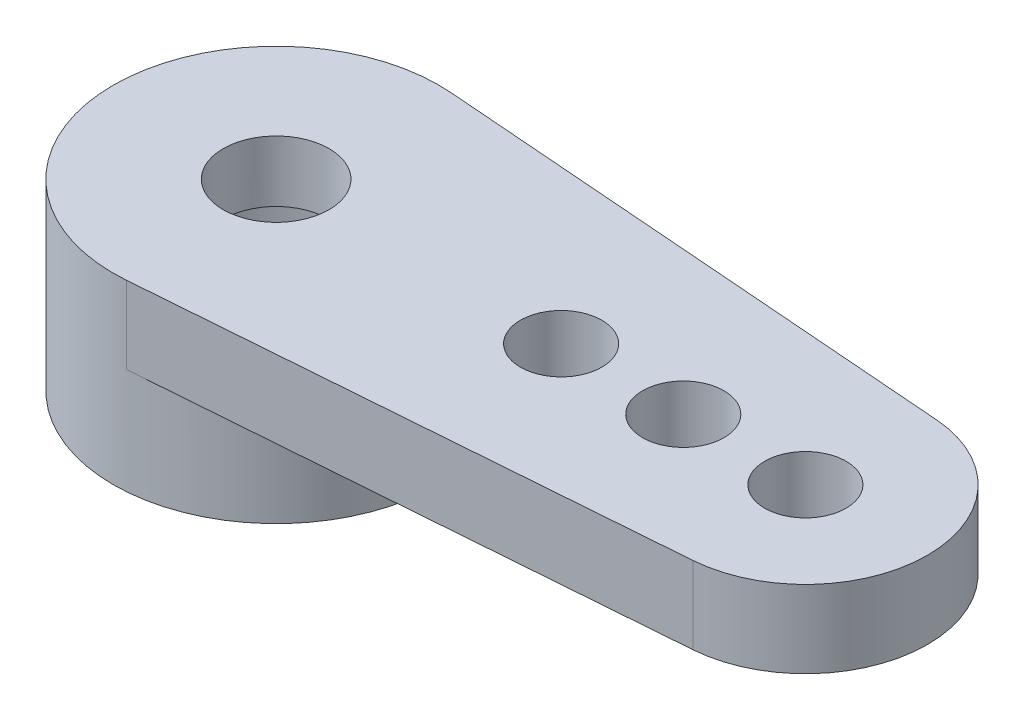
from build123d import *

# Parameters (mm, degrees)
SKETCH_1_R          = 4
SKETCH_1_R_2        = 1.3
EXTRUDE_1_DEPTH     = 4.5
SKETCH_2_R          = 1
EXTRUDE_2_DEPTH     = 1.9
SKETCH_3_R          = 3
CUT_EXTRUDE_1_DEPTH = 3


with BuildPart() as part:
    # 草图1 → 凸台-拉伸1 (new body)
    with BuildSketch(Plane(origin=(0, 0, 0), x_dir=(1, 0, 0), z_dir=(0, 1, 0))):
        Circle(SKETCH_1_R)
        Circle(SKETCH_1_R_2, mode=Mode.SUBTRACT)
    extrude(amount=EXTRUDE_1_DEPTH)

    # 草图2 → 凸台-拉伸2 (add)
    with BuildSketch(Plane(origin=(0, 4.5, 0), x_dir=(1, 0, 0), z_dir=(0, 1, 0))):
        with BuildLine():
            Line((13.230769231, 2.991111092), (0.307692308, 3.988148122))
            ThreePointArc((0.307692308, 3.988148122), (4, 0), (0.307692308, -3.988148122))
            Line((0.307692308, -3.988148122), (13.230769231, -2.991111092))
            ThreePointArc((13.230769231, -2.991111092), (16, 0), (13.230769231, 2.991111092))
        make_face()
        with Locations((10, 0)):
            Circle(SKETCH_2_R, mode=Mode.SUBTRACT)
        with Locations((7, 0)):
            Circle(SKETCH_2_R, mode=Mode.SUBTRACT)
        with Locations((13, 0)):
            Circle(SKETCH_2_R, mode=Mode.SUBTRACT)
    extrude(amount=-EXTRUDE_2_DEPTH)

    # 草图3 → 切除-拉伸1 (cut)
    with BuildSketch(Plane.XZ):
        Circle(SKETCH_3_R)
    extrude(amount=-CUT_EXTRUDE_1_DEPTH, mode=Mode.SUBTRACT)


solid = part.part
